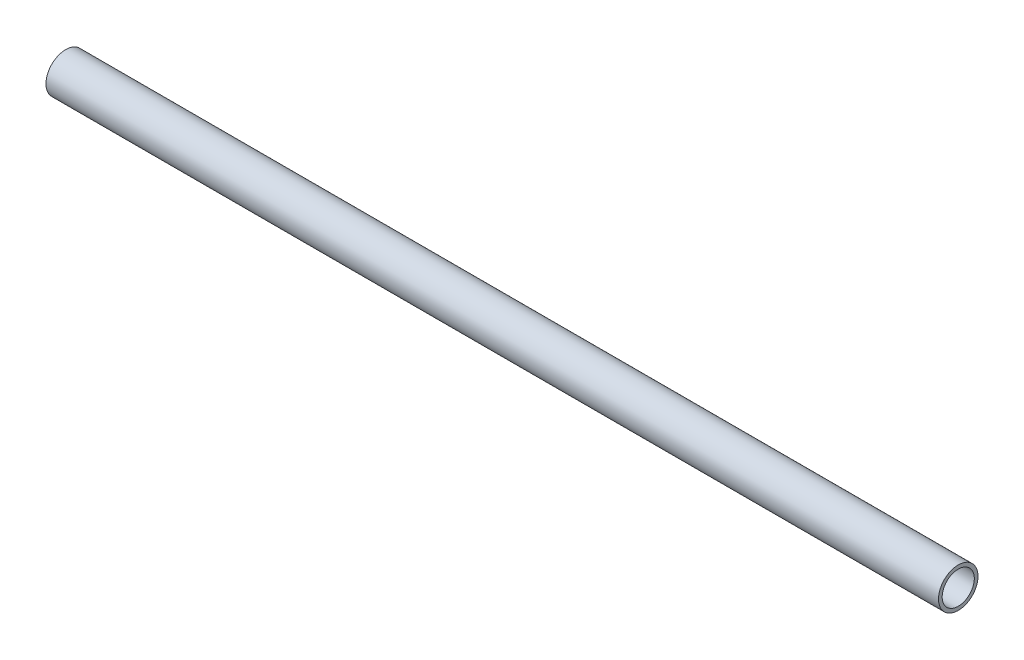
from build123d import *

# Parameters (mm, degrees)
SKETCH1_R                = 7.9375
SKETCH1_R_2              = 6.4643
STRUCTURAL_MEMBER1_DEPTH = 358.775


with BuildPart() as part:
    # Sketch1 → Structural Member1 (new body)
    with BuildSketch(Plane.YZ):
        Circle(SKETCH1_R)
        Circle(SKETCH1_R_2, mode=Mode.SUBTRACT)
    extrude(amount=STRUCTURAL_MEMBER1_DEPTH)


solid = part.part
